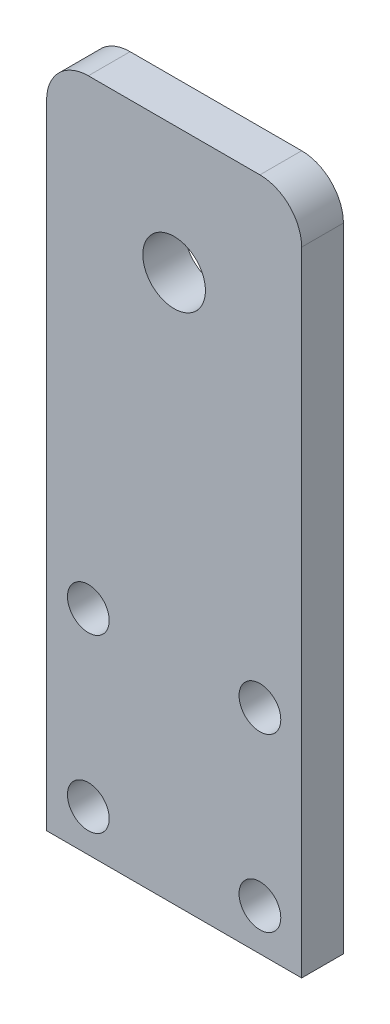
from build123d import *

# Parameters (mm, degrees)
SKETCH1_R           = 4.7625
SKETCH1_W           = 38.80104
SKETCH1_H           = 38.80104
SKETCH1_R_2         = 3.175
BOSS_EXTRUDE1_DEPTH = 6.35
FILLET1_R           = 6.35


with BuildPart() as part:
    # Sketch1 → Boss-Extrude1 (new body)
    with BuildSketch(Plane.XY):
        Polygon((19.40052, 19.40052), (-19.40052, 19.40052), (-19.40052, 44.4390625), (-19.40052, 83.2401025), (19.40052, 83.2401025), (19.40052, 44.4390625), align=None)
        with Locations((0, 63.8395825)):
            Circle(SKETCH1_R, mode=Mode.SUBTRACT)
        Rectangle(SKETCH1_W, SKETCH1_H)
        with Locations((13.05052, -13.05052)):
            Circle(SKETCH1_R_2, mode=Mode.SUBTRACT)
        with Locations((-13.05052, -13.05052)):
            Circle(SKETCH1_R_2, mode=Mode.SUBTRACT)
        with Locations((-13.05052, 13.05052)):
            Circle(SKETCH1_R_2, mode=Mode.SUBTRACT)
        with Locations((13.05052, 13.05052)):
            Circle(SKETCH1_R_2, mode=Mode.SUBTRACT)
    extrude(amount=BOSS_EXTRUDE1_DEPTH)

    # Fillet1
    fillet1_edges = [part.edges().sort_by_distance(p)[0] for p in [
        (-19.40052, 83.2401025, 3.175),
        (19.40052, 83.2401025, 3.175),
    ]]
    fillet(fillet1_edges, radius=FILLET1_R)


solid = part.part
